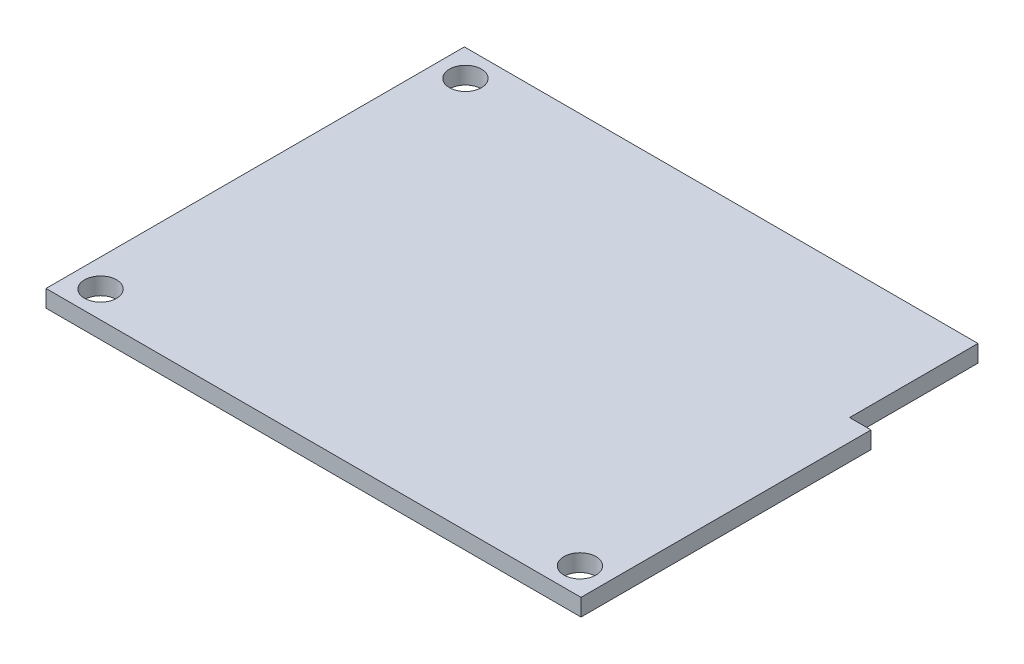
from build123d import *

# Parameters (mm, degrees)
SKETCH1_R           = 1.5
BOSS_EXTRUDE1_DEPTH = 1.6


with BuildPart() as part:
    # Sketch1 → Boss-Extrude1 (new body)
    with BuildSketch(Plane(origin=(0, 0, 0), x_dir=(1, 0, 0), z_dir=(0, 1, 0))):
        Polygon((23, 19.55), (23, 7.55), (25, 7.55), (25, -19.55), (-25, -19.55), (-25, 19.55), align=None)
        with Locations((-22.4, 17.05)):
            Circle(SKETCH1_R, mode=Mode.SUBTRACT)
        with Locations((-22.4, -17.05)):
            Circle(SKETCH1_R, mode=Mode.SUBTRACT)
        with Locations((22.4, -17.05)):
            Circle(SKETCH1_R, mode=Mode.SUBTRACT)
    extrude(amount=BOSS_EXTRUDE1_DEPTH)


solid = part.part
